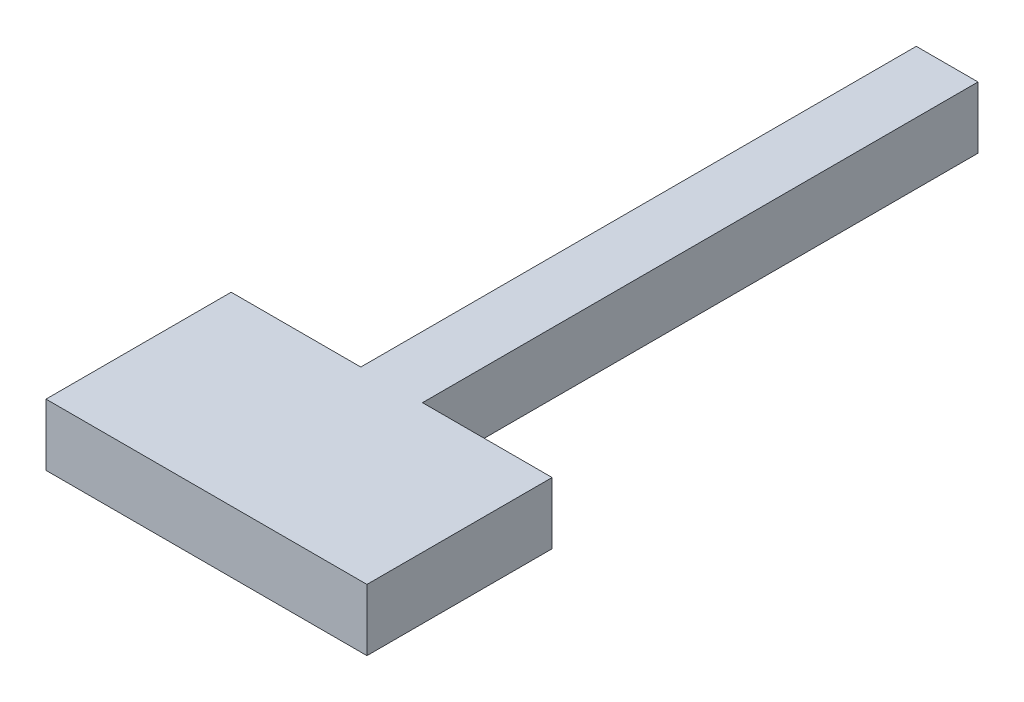
from build123d import *

# Parameters (mm, degrees)
SKETCH1_W           = 5
SKETCH1_H           = 5
BOSS_EXTRUDE1_DEPTH = 45
SKETCH2_W           = 26
SKETCH2_H           = 5
BOSS_EXTRUDE2_DEPTH = 15
SKETCH3_R           = 1.5
CUT_EXTRUDE1_DEPTH  = 5


with BuildPart() as part:
    # Sketch1 → Boss-Extrude1 (new body)
    with BuildSketch(Plane.XY):
        with Locations((-24.851797929, 5.221320947)):
            Rectangle(SKETCH1_W, SKETCH1_H)
    extrude(amount=BOSS_EXTRUDE1_DEPTH)

    # Sketch2 → Boss-Extrude2 (add)
    with BuildSketch(Plane.XY.offset(45)):
        with Locations((-24.851797929, 5.221320947)):
            Rectangle(SKETCH2_W, SKETCH2_H)
    extrude(amount=BOSS_EXTRUDE2_DEPTH)

    # Sketch3 → Cut-Extrude1 (cut)
    with BuildSketch(Plane(origin=(0, 0, 0), x_dir=(-1, 0, 0), z_dir=(0, 0, -1))):
        with Locations((24.851797929, 5.221320947)):
            Circle(SKETCH3_R)
    extrude(amount=-CUT_EXTRUDE1_DEPTH, mode=Mode.SUBTRACT)


solid = part.part
